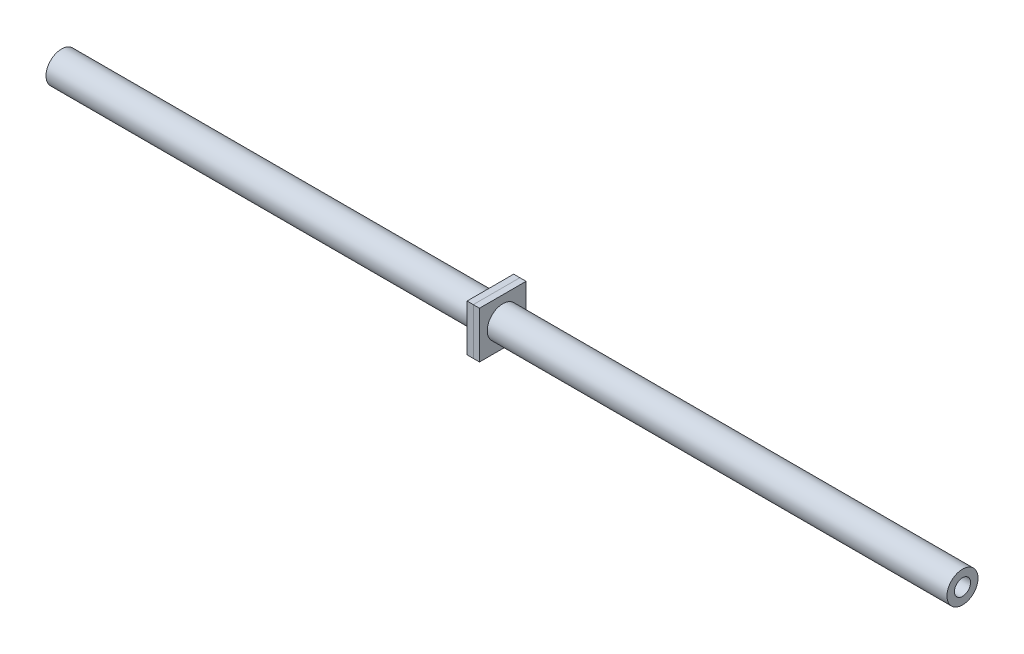
from build123d import *

# Parameters (mm, degrees)
SKETCH11_R            = 6.35
SKETCH11_R_2          = 3.302
PULL_ROD_MEMBER_DEPTH = 368.21482491
PULL_START            = 177.8
SKETCH12_W            = 19.05
SKETCH12_H            = 19.05
SKETCH12_R            = 6.35
PULL_ROD_NUT_1_DEPTH  = 2.54
SKETCH13_W            = 19.05
SKETCH13_H            = 19.05
SKETCH13_R            = 6.35
PULL_ROD_NUT_2_DEPTH  = 2.54


with BuildPart() as part:
    # Sketch11 → Pull Rod Member (new body)
    with BuildSketch(Plane.YZ):
        Circle(SKETCH11_R)
        Circle(SKETCH11_R_2, mode=Mode.SUBTRACT)
    extrude(amount=PULL_ROD_MEMBER_DEPTH)


with BuildPart() as body_2:
    # Sketch12 → Pull Rod Nut 1 (new body)
    with BuildSketch(Plane(origin=(0, 0, 0), x_dir=(0, 0, -1), z_dir=(1, 0, 0)).offset(PULL_START)):
        Rectangle(SKETCH12_W, SKETCH12_H)
        Circle(SKETCH12_R, mode=Mode.SUBTRACT)
    extrude(amount=PULL_ROD_NUT_1_DEPTH)


with BuildPart() as body_3:
    # Sketch13 → Pull Rod Nut 2 (new body)
    with BuildSketch(Plane(origin=(0, 0, 0), x_dir=(0, 0, -1), z_dir=(1, 0, 0)).offset(PULL_START)):
        Rectangle(SKETCH13_W, SKETCH13_H)
        with Locations(Location((0, 0, 0), (0, 0, 180))):
            Circle(SKETCH13_R, mode=Mode.SUBTRACT)
    extrude(amount=-PULL_ROD_NUT_2_DEPTH)


solid = Compound([part.part, body_2.part, body_3.part])
